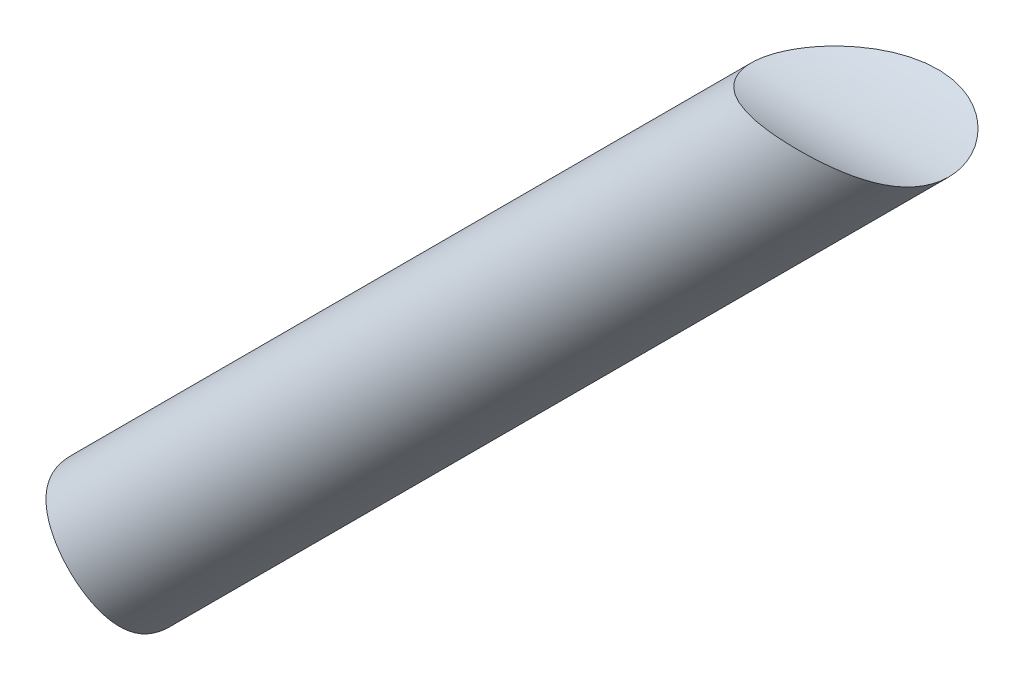
from build123d import *

# Parameters (mm, degrees)
SKETCH9_R                       = 9
SKETCH9_R_2                     = 8
BOSS_EXTRUDE1_DEPTH             = 20
SKETCH10_W                      = 4.934959926
SKETCH10_H                      = 0.2
CUT_EXTRUDE1_DEPTH              = 20
SKETCH11_R                      = 6
BOSS_EXTRUDE2_DEPTH             = 100
BOSS_EXTRUDE2_DIRECTION_2_REACH = 23.728
SKETCH12_R                      = 6
BOSS_EXTRUDE3_DEPTH             = 100
BOSS_EXTRUDE3_DIRECTION_2_REACH = 74.864
SKETCH14_R                      = 12.5
CUT_EXTRUDE3_DEPTH              = 82.317279836
CUT_EXTRUDE3_DEPTH_BACK         = 82.317279836
CUT_EXTRUDE4_DEPTH              = 21.0000001


with BuildPart() as part:
    # Sketch9 → Boss-Extrude1 (new body)
    with BuildSketch(Plane.XY):
        Circle(SKETCH9_R)
        Circle(SKETCH9_R_2, mode=Mode.SUBTRACT)
    extrude(amount=BOSS_EXTRUDE1_DEPTH)

    # Sketch10 → Cut-Extrude1 (cut)
    with BuildSketch(Plane.XY.offset(20)):
        with Locations((8, 0)):
            Rectangle(SKETCH10_W, SKETCH10_H)
    extrude(amount=-CUT_EXTRUDE1_DEPTH, mode=Mode.SUBTRACT)

    # Sketch11 → Boss-Extrude2 (add)
    with BuildSketch(Plane(origin=(-6.363961031, 6.363961031, 0), x_dir=(0, 0, -1), z_dir=(-0.707106781, 0.707106781, 0))):
        with Locations((-10, 0)):
            Circle(SKETCH11_R)
    extrude(amount=BOSS_EXTRUDE2_DEPTH)

    # Sketch11 → Boss-Extrude2 direction 2 (add, up to next)
    with BuildSketch(Plane(origin=(-6.363961031, 6.363961031, 0), x_dir=(0, 0, -1), z_dir=(-0.707106781, 0.707106781, 0)), mode=Mode.PRIVATE) as boss_extrude2_direction_2_sk1:
        with Locations((-10, 0)):
            Circle(SKETCH11_R)
    boss_extrude2_direction_2_tool1 = extrude(boss_extrude2_direction_2_sk1.sketch, amount=-BOSS_EXTRUDE2_DIRECTION_2_REACH, mode=Mode.PRIVATE) - part.part
    add(boss_extrude2_direction_2_tool1.solids().sort_by_distance((-6.363961, 6.363961, 10))[0])
    add(boss_extrude2_direction_2_tool1.solids().sort_by_distance((-6.363961, 6.363961, 10))[1])

    # Sketch12 → Boss-Extrude3 (add)
    with BuildSketch(Plane(origin=(6.363961031, 6.363961031, 0), x_dir=(0, 0, -1), z_dir=(0.707106781, 0.707106781, 0))):
        with Locations((-10, 0)):
            Circle(SKETCH12_R)
    extrude(amount=BOSS_EXTRUDE3_DEPTH)

    # Sketch12 → Boss-Extrude3 direction 2 (add, up to next)
    with BuildSketch(Plane(origin=(6.363961031, 6.363961031, 0), x_dir=(0, 0, -1), z_dir=(0.707106781, 0.707106781, 0)), mode=Mode.PRIVATE) as boss_extrude3_direction_2_sk1:
        with Locations((-10, 0)):
            Circle(SKETCH12_R)
    boss_extrude3_direction_2_tool1 = extrude(boss_extrude3_direction_2_sk1.sketch, amount=-BOSS_EXTRUDE3_DIRECTION_2_REACH, mode=Mode.PRIVATE) - part.part
    add(boss_extrude3_direction_2_tool1.solids().sort_by_distance((6.363961, 6.363961, 10))[0])
    add(boss_extrude3_direction_2_tool1.solids().sort_by_distance((6.363961, 6.363961, 10))[1])

    # Sketch14 → Cut-Extrude3 (cut, two sides)
    with BuildSketch(Plane(origin=(0, 0, 0), x_dir=(0, 0, -1), z_dir=(1, 0, 0))) as cut_extrude3_sk:
        with Locations((-10, 79.9)):
            Circle(SKETCH14_R)
    extrude(amount=CUT_EXTRUDE3_DEPTH, mode=Mode.SUBTRACT)
    extrude(cut_extrude3_sk.sketch, amount=-CUT_EXTRUDE3_DEPTH_BACK, mode=Mode.SUBTRACT)

    # Sketch15 → Cut-Extrude4 (cut, through all)
    with BuildSketch(Plane.XY.offset(20)):
        with BuildLine():
            Line((-9, 0), (-109.979142128, 0))
            Line((-109.979142128, 0), (-109.979142128, 78.923804152))
            Line((-109.979142128, 78.923804152), (0, 78.923804152))
            Line((0, 78.923804152), (0, 9))
            ThreePointArc((0, 9), (6.363961031, -6.363961031), (-9, 0))
        make_face()
    extrude(amount=-CUT_EXTRUDE4_DEPTH, mode=Mode.SUBTRACT)


solid = part.part
